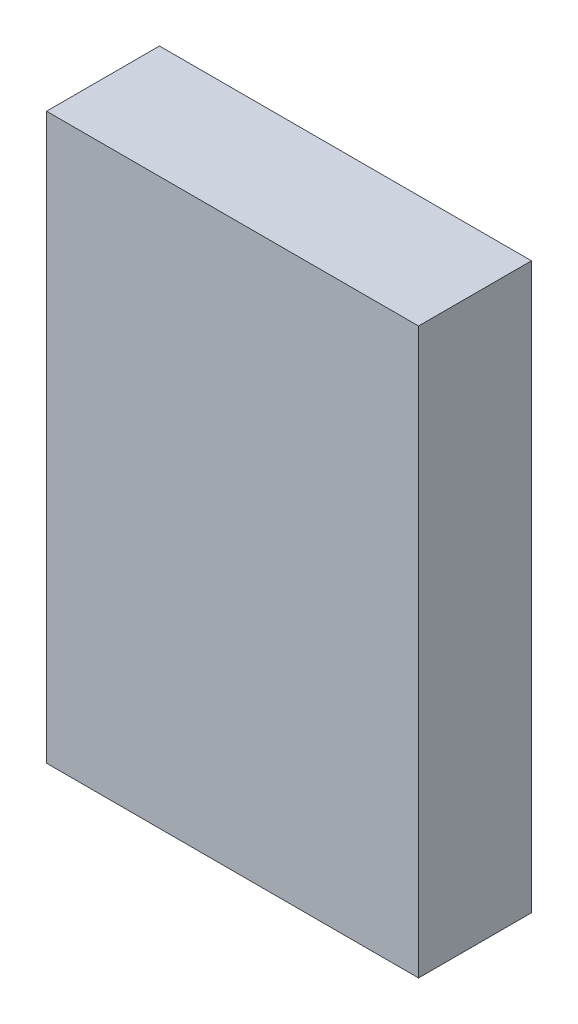
from build123d import *

# Parameters (mm, degrees)
SKETCH1_W           = 56
SKETCH1_H           = 85
BOSS_EXTRUDE1_DEPTH = 17


with BuildPart() as part:
    # Sketch1 → Boss-Extrude1 (new body)
    with BuildSketch(Plane.XY):
        Rectangle(SKETCH1_W, SKETCH1_H)
    extrude(amount=BOSS_EXTRUDE1_DEPTH)


solid = part.part
